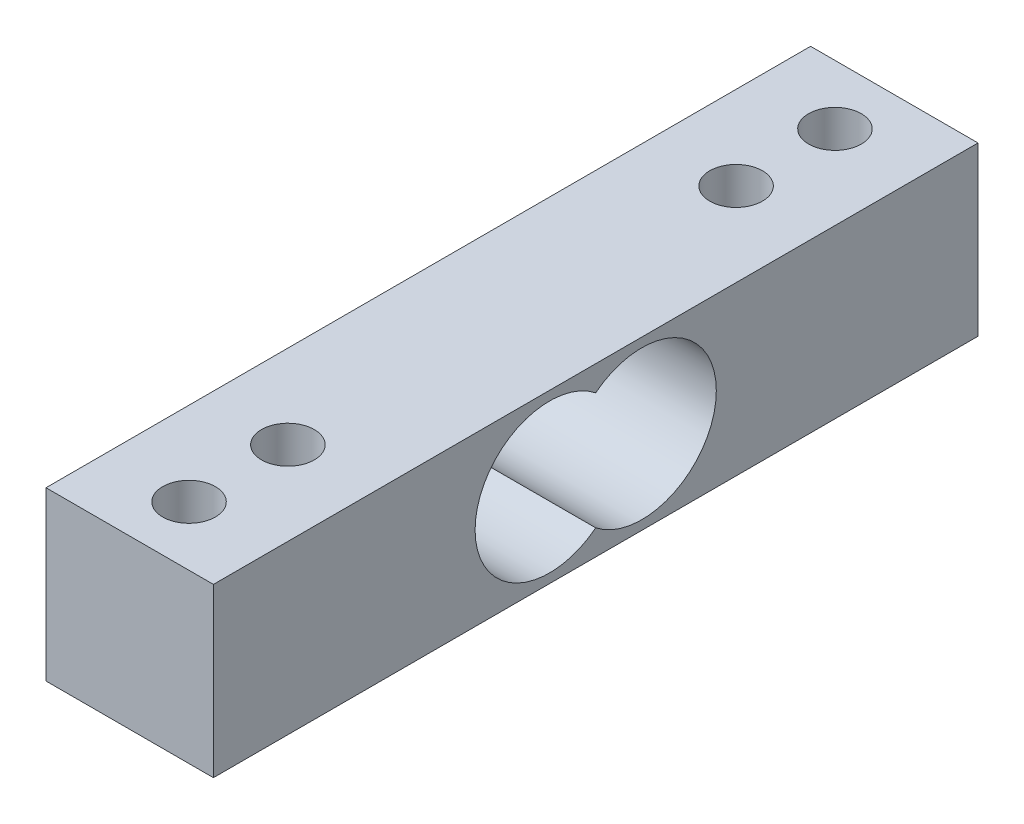
from build123d import *

# Parameters (mm, degrees)
ESQUISSE1_W             = 12.7
ESQUISSE1_H             = 12.7
BOSS_EXTRU_1_DEPTH      = 29
ESQUISSE2_R             = 2
ENL_V_MAT_EXTRU_1_DEPTH = 33.289510681
ENL_V_MAT_EXTRU_2_DEPTH = 33.289510681


with BuildPart() as part:
    # Esquisse1 → Boss.-Extru.1 (new, symmetric)
    with BuildSketch(Plane.XY):
        Rectangle(ESQUISSE1_W, ESQUISSE1_H)
    extrude(amount=BOSS_EXTRU_1_DEPTH, both=True)

    # Esquisse2 → Enlèv. mat.-Extru.1 (cut, through all)
    with BuildSketch(Plane(origin=(0, 6.35, 0), x_dir=(1, 0, 0), z_dir=(0, 1, 0))):
        with Locations((0, 24.5)):
            Circle(ESQUISSE2_R)
        with Locations((0, 17)):
            Circle(ESQUISSE2_R)
        with Locations((0, -17)):
            Circle(ESQUISSE2_R)
        with Locations((0, -24.5)):
            Circle(ESQUISSE2_R)
    extrude(amount=-ENL_V_MAT_EXTRU_1_DEPTH, mode=Mode.SUBTRACT)

    # Esquisse3 → Enlèv. mat.-Extru.2 (cut, through all)
    with BuildSketch(Plane(origin=(6.35, 0, 0), x_dir=(0, 0, -1), z_dir=(1, 0, 0))):
        with BuildLine():
            ThreePointArc((0, 4.435369207), (-9.15, 0), (0, -4.435369207))
            ThreePointArc((0, -4.435369207), (9.15, 0), (0, 4.435369207))
        make_face()
    extrude(amount=-ENL_V_MAT_EXTRU_2_DEPTH, mode=Mode.SUBTRACT)


solid = part.part
